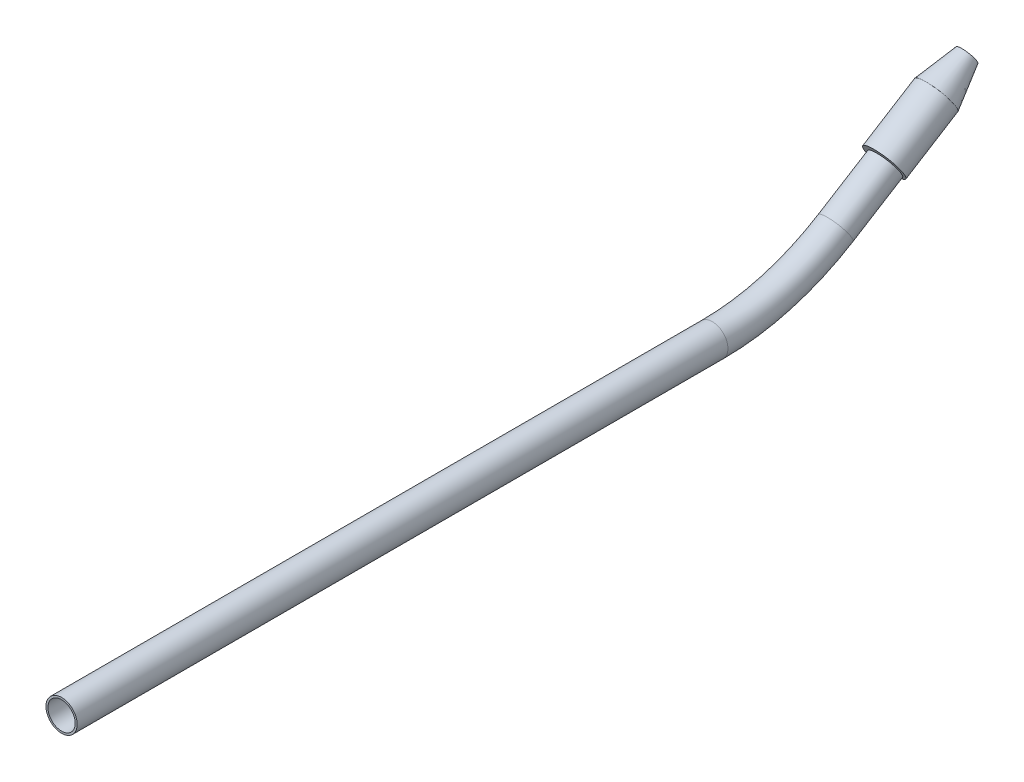
from build123d import *

# Parameters (mm, degrees)
SKETCH2_R   = 2
SKETCH2_R_2 = 1.75


with BuildPart() as part:
    # Sweep1: sweep along a path in Sketch1
    with BuildLine(Plane(origin=(0, 0, 0), x_dir=(0, 0, -1), z_dir=(1, 0, 0))) as sweep1_path:
        Line((-7.82934114, 0), (75.673647507, 0))
        ThreePointArc((75.673647507, 0), (83.897502379, 1.149207792), (91.491296044, 4.508785931))
        Line((91.491296044, 4.508785931), (97.844646472, 8.451127156))
    # Sketch2 → Sweep1 (sweep)
    with BuildSketch(Plane.XY):
        Circle(SKETCH2_R)
        Circle(SKETCH2_R_2, mode=Mode.SUBTRACT)
    sweep(path=sweep1_path.line)


with BuildPart() as body_2:
    # Sketch3 → Revolve1 (revolve)
    with BuildSketch(Plane(origin=(0, 0, 0), x_dir=(0, 0, -1), z_dir=(1, 0, 0))):
        Polygon((98.063364296, 8.135998244), (99.042203981, 6.565358226), (105.717334971, 10.725371372), (109.005369397, 14.219041289), (108.674940143, 14.749245996), align=None)
    revolve(axis=Axis((0, -57.121033946, 7.82934114), (0, 0.528906522, -0.848680087)))


solid = Compound([part.part, body_2.part])
